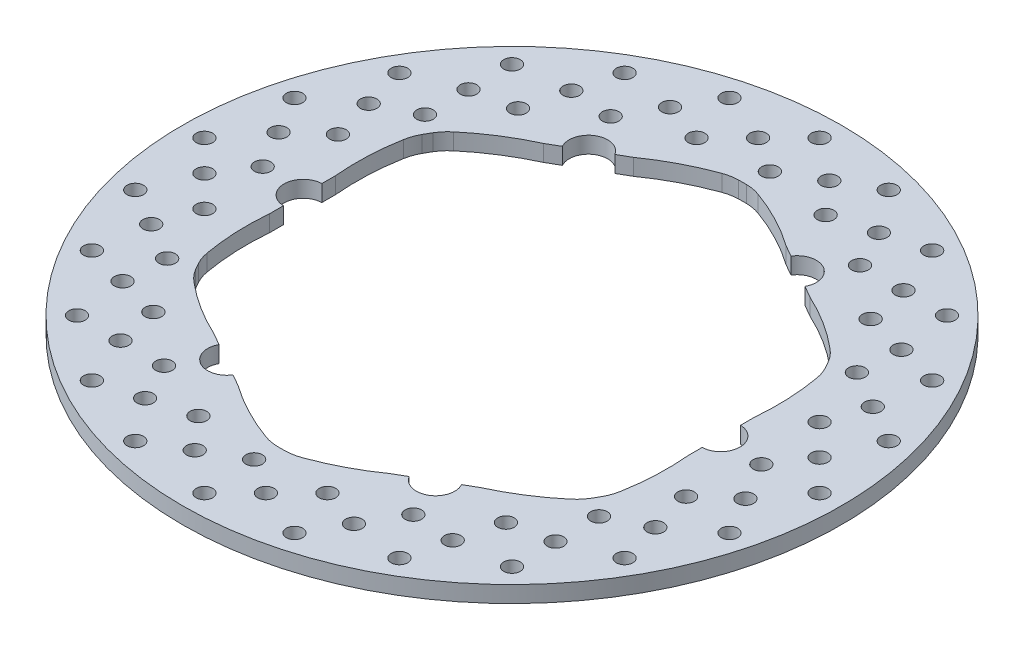
from build123d import *

# Parameters (mm, degrees)
SKETCH1_R                = 95.25
SKETCH1_R_2              = 66.675
BOSS_EXTRUDE2_DEPTH      = 2.38125
SKETCH2_R                = 2.38125
CUT_EXTRUDE1_DEPTH       = 135.788005424
BOSS_EXTRUDE3_DEPTH      = 2.38125
FILLET1_R                = 12.7
CIRPATTERN1_COUNT        = 6
FILLET1_OF_CIRPATTERN1_R = 12.7


with BuildPart() as part:
    # Sketch1 → Boss-Extrude2 (new, symmetric)
    with BuildSketch(Plane(origin=(0, 0, 0), x_dir=(1, 0, 0), z_dir=(0, 1, 0))):
        Circle(SKETCH1_R)
        Circle(SKETCH1_R_2, mode=Mode.SUBTRACT)
    extrude(amount=BOSS_EXTRUDE2_DEPTH, both=True)

    # Sketch2 → Cut-Extrude1 (cut, through all)
    with BuildSketch(Plane.XZ.offset(2.38125)):
        with Locations((0, 88.9)):
            Circle(SKETCH2_R)
        with Locations((8.89, 80.01)):
            Circle(SKETCH2_R)
        with Locations((17.78, 71.12)):
            Circle(SKETCH2_R)
        with Locations((29.295192394, 74.98282405)):
            Circle(SKETCH2_R)
        with Locations((35.581371679, 64.094842144)):
            Circle(SKETCH2_R)
        with Locations((23.00901311, 85.870805957)):
            Circle(SKETCH2_R)
        with Locations((47.70396584, 64.845692557)):
            Circle(SKETCH2_R)
        with Locations((50.957931679, 52.701726717)):
            Circle(SKETCH2_R)
        with Locations((44.45, 76.989658396)):
            Circle(SKETCH2_R)
        with Locations((62.861792847, 50.289434278)):
            Circle(SKETCH2_R)
        with Locations((62.861792847, 37.717075708)):
            Circle(SKETCH2_R)
        with Locations((62.861792847, 62.861792847)):
            Circle(SKETCH2_R)
        with Locations((73.735692557, 32.30603416)):
            Circle(SKETCH2_R)
        with Locations((70.481726717, 20.162068321)):
            Circle(SKETCH2_R)
        with Locations((76.989658396, 44.45)):
            Circle(SKETCH2_R)
        with Locations((79.584626672, 12.121031203)):
            Circle(SKETCH2_R)
        with Locations((73.298447388, 1.233049296)):
            Circle(SKETCH2_R)
        with Locations((85.870805957, 23.00901311)):
            Circle(SKETCH2_R)
        with Locations((80.01, -8.89)):
            Circle(SKETCH2_R)
        with Locations((71.12, -17.78)):
            Circle(SKETCH2_R)
        with Locations((88.9, 0)):
            Circle(SKETCH2_R)
        with Locations((74.98282405, -29.295192394)):
            Circle(SKETCH2_R)
        with Locations((64.094842144, -35.581371679)):
            Circle(SKETCH2_R)
        with Locations((85.870805957, -23.00901311)):
            Circle(SKETCH2_R)
        with Locations((64.845692557, -47.70396584)):
            Circle(SKETCH2_R)
        with Locations((52.701726717, -50.957931679)):
            Circle(SKETCH2_R)
        with Locations((76.989658396, -44.45)):
            Circle(SKETCH2_R)
        with Locations((50.289434278, -62.861792847)):
            Circle(SKETCH2_R)
        with Locations((37.717075709, -62.861792847)):
            Circle(SKETCH2_R)
        with Locations((62.861792847, -62.861792847)):
            Circle(SKETCH2_R)
        with Locations((32.30603416, -73.735692557)):
            Circle(SKETCH2_R)
        with Locations((20.162068321, -70.481726717)):
            Circle(SKETCH2_R)
        with Locations((44.45, -76.989658396)):
            Circle(SKETCH2_R)
        with Locations((12.121031203, -79.584626672)):
            Circle(SKETCH2_R)
        with Locations((1.233049296, -73.298447388)):
            Circle(SKETCH2_R)
        with Locations((23.00901311, -85.870805957)):
            Circle(SKETCH2_R)
        with Locations((-8.89, -80.01)):
            Circle(SKETCH2_R)
        with Locations((-17.78, -71.12)):
            Circle(SKETCH2_R)
        with Locations((0, -88.9)):
            Circle(SKETCH2_R)
        with Locations((-29.295192394, -74.98282405)):
            Circle(SKETCH2_R)
        with Locations((-35.581371679, -64.094842144)):
            Circle(SKETCH2_R)
        with Locations((-23.00901311, -85.870805957)):
            Circle(SKETCH2_R)
        with Locations((-47.70396584, -64.845692557)):
            Circle(SKETCH2_R)
        with Locations((-50.957931679, -52.701726717)):
            Circle(SKETCH2_R)
        with Locations((-44.45, -76.989658396)):
            Circle(SKETCH2_R)
        with Locations((-62.861792847, -50.289434278)):
            Circle(SKETCH2_R)
        with Locations((-62.861792847, -37.717075708)):
            Circle(SKETCH2_R)
        with Locations((-62.861792847, -62.861792847)):
            Circle(SKETCH2_R)
        with Locations((-73.735692557, -32.30603416)):
            Circle(SKETCH2_R)
        with Locations((-70.481726717, -20.162068321)):
            Circle(SKETCH2_R)
        with Locations((-76.989658396, -44.45)):
            Circle(SKETCH2_R)
        with Locations((-79.584626672, -12.121031203)):
            Circle(SKETCH2_R)
        with Locations((-73.298447388, -1.233049296)):
            Circle(SKETCH2_R)
        with Locations((-85.870805957, -23.00901311)):
            Circle(SKETCH2_R)
        with Locations((-80.01, 8.89)):
            Circle(SKETCH2_R)
        with Locations((-71.12, 17.78)):
            Circle(SKETCH2_R)
        with Locations((-88.9, 0)):
            Circle(SKETCH2_R)
        with Locations((-74.98282405, 29.295192394)):
            Circle(SKETCH2_R)
        with Locations((-64.094842144, 35.581371679)):
            Circle(SKETCH2_R)
        with Locations((-85.870805957, 23.00901311)):
            Circle(SKETCH2_R)
        with Locations((-64.845692557, 47.70396584)):
            Circle(SKETCH2_R)
        with Locations((-52.701726717, 50.957931679)):
            Circle(SKETCH2_R)
        with Locations((-76.989658396, 44.45)):
            Circle(SKETCH2_R)
        with Locations((-50.289434278, 62.861792847)):
            Circle(SKETCH2_R)
        with Locations((-37.717075708, 62.861792847)):
            Circle(SKETCH2_R)
        with Locations((-62.861792847, 62.861792847)):
            Circle(SKETCH2_R)
        with Locations((-32.30603416, 73.735692557)):
            Circle(SKETCH2_R)
        with Locations((-20.162068321, 70.481726717)):
            Circle(SKETCH2_R)
        with Locations((-44.45, 76.989658396)):
            Circle(SKETCH2_R)
        with Locations((-12.121031203, 79.584626672)):
            Circle(SKETCH2_R)
        with Locations((-1.233049296, 73.298447388)):
            Circle(SKETCH2_R)
        with Locations((-23.00901311, 85.870805957)):
            Circle(SKETCH2_R)
    extrude(amount=-CUT_EXTRUDE1_DEPTH, mode=Mode.SUBTRACT)

    # Sketch3 → Boss-Extrude3 (add, symmetric)
    with BuildSketch(Plane(origin=(0, 0, 0), x_dir=(1, 0, 0), z_dir=(0, 1, 0))):
        with BuildLine():
            Line((-60.5028, 5.553404471), (-60.5028, 9.525))
            ThreePointArc((-60.5028, 9.525), (-60.6788531, 20.047105636), (-59.300297006, 30.48))
            ThreePointArc((-59.300297006, 30.48), (-66.675, 0), (-59.300297006, -30.48))
            ThreePointArc((-59.300297006, -30.48), (-60.6788531, -20.047105636), (-60.5028, -9.525))
            Line((-60.5028, -9.525), (-60.5028, -5.553404471))
            ThreePointArc((-60.5028, -5.553404471), (-65.88125, 0), (-60.5028, 5.553404471))
        make_face()
    boss_extrude3 = extrude(amount=BOSS_EXTRUDE3_DEPTH, both=True)

    # Fillet1
    fillet1_edges = [part.edges().sort_by_distance(p)[0] for p in [
        (-59.300297006, 0, 30.48),
        (-59.300297006, 0, -30.48),
    ]]
    fillet(fillet1_edges, radius=FILLET1_R)

    # CirPattern1: Boss-Extrude3 ×6 about axis
    cirpattern1_axis = Axis((0, 83.345574676, 0), (0, -1, 0))
    for i in range(1, CIRPATTERN1_COUNT):
        add(boss_extrude3.rotate(cirpattern1_axis, i * 360 / CIRPATTERN1_COUNT))

    # Fillet1 of CirPattern1
    fillet1_of_cirpattern1_edges = [part.edges().sort_by_distance(p)[0] for p in [
        (-56.04660281, 0, -36.115563659),
        (-3.253694196, 0, -66.595563659),
        (3.253694196, 0, -66.595563659),
        (56.04660281, 0, -36.115563659),
        (59.300297006, 0, -30.48),
        (59.300297006, 0, 30.48),
        (56.04660281, 0, 36.115563659),
        (3.253694196, 0, 66.595563659),
        (-3.253694196, 0, 66.595563659),
        (-56.04660281, 0, 36.115563659),
    ]]
    fillet(fillet1_of_cirpattern1_edges, radius=FILLET1_OF_CIRPATTERN1_R)


solid = part.part
